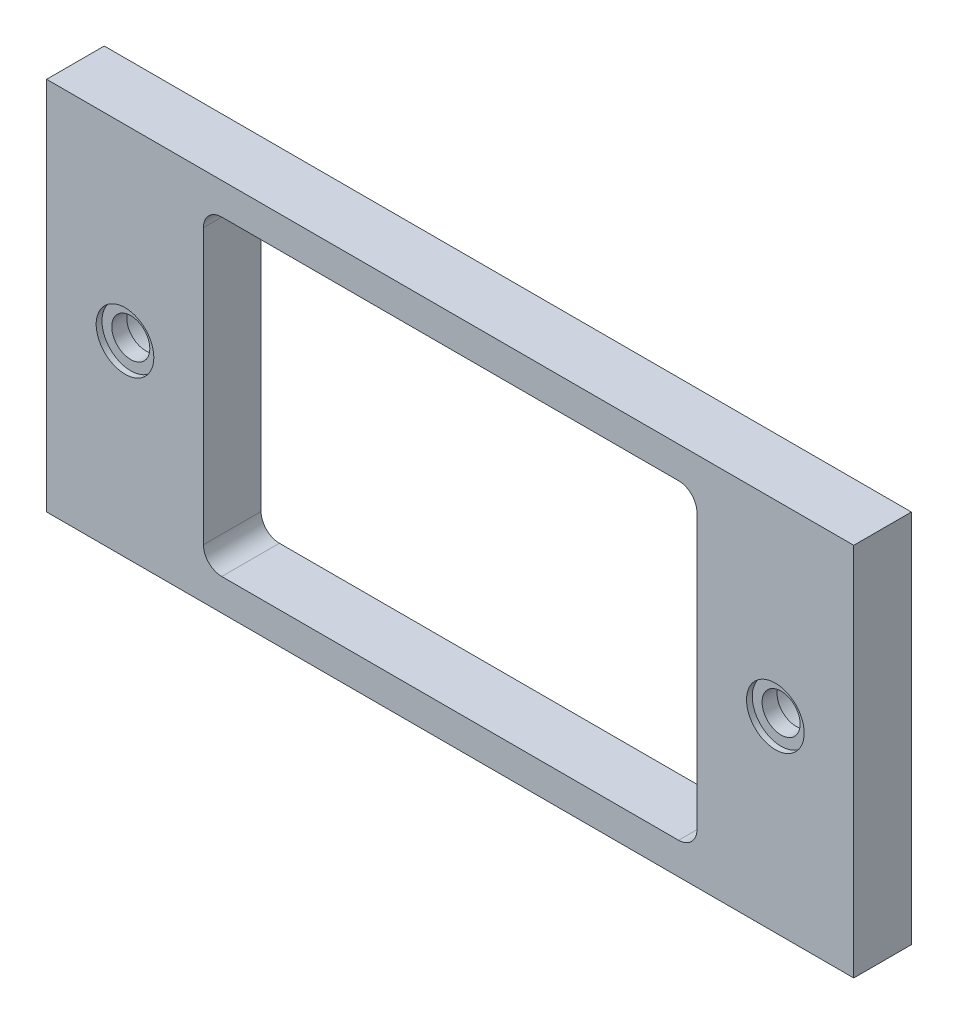
from build123d import *

# Parameters (mm, degrees)
SKETCH_1_W                   = 140
SKETCH_1_H                   = 65
EXTRUDE_1_DEPTH              = 10
SKETCH_2_W                   = 85.6
SKETCH_2_H                   = 54
CUT_EXTRUDE_1_DEPTH          = 11
FILLET_1_R                   = 3.18
HOLE_WIZARD_M6_1_D           = 6.6
HOLE_WIZARD_M6_1_DEPTH       = 15
HOLE_WIZARD_M6_1_CBORE_D     = 11
HOLE_WIZARD_M6_1_CBORE_DEPTH = 6.4
HOLE_WIZARD_M6_1_TIP         = 1.982840043
SKETCH_6_R                   = 5
CUT_EXTRUDE_3_DEPTH          = 1


with BuildPart() as part:
    # 草图1 → 凸台-拉伸1 (new body)
    with BuildSketch(Plane.XY):
        with Locations((70, 32.5)):
            Rectangle(SKETCH_1_W, SKETCH_1_H)
    extrude(amount=EXTRUDE_1_DEPTH)

    # 草图2 → 切除-拉伸1 (cut, through all)
    with BuildSketch(Plane.XY.offset(10)):
        with Locations((70, 32.5)):
            Rectangle(SKETCH_2_W, SKETCH_2_H)
    extrude(amount=-CUT_EXTRUDE_1_DEPTH, mode=Mode.SUBTRACT)

    # 圆角1
    fillet_1_edges = [part.edges().sort_by_distance(p)[0] for p in [
        (27.2, 5.5, 5),
        (27.2, 59.5, 5),
        (112.8, 59.5, 5),
        (112.8, 5.5, 5),
    ]]
    fillet(fillet_1_edges, radius=FILLET_1_R)

    # M6 六角凹头螺钉的柱形沉头孔1
    with Locations(Plane(origin=(0, 0, 0), x_dir=(-1, 0, 0), z_dir=(0, 0, -1))):
        with Locations((-126.4, 32.5), (-13.6, 32.5)):
            CounterBoreHole(HOLE_WIZARD_M6_1_D / 2, HOLE_WIZARD_M6_1_CBORE_D / 2, HOLE_WIZARD_M6_1_CBORE_DEPTH, depth=HOLE_WIZARD_M6_1_DEPTH)
            with Locations((0, 0, -(HOLE_WIZARD_M6_1_DEPTH + HOLE_WIZARD_M6_1_TIP / 2))):  # 118° drill point
                Cone(0, HOLE_WIZARD_M6_1_D / 2, HOLE_WIZARD_M6_1_TIP, mode=Mode.SUBTRACT)

    # 草图6 → 切除-拉伸3 (cut)
    with BuildSketch(Plane.XY.offset(10)):
        with Locations((13.6, 32.5)):
            Circle(SKETCH_6_R)
        with Locations((126.4, 32.5)):
            Circle(SKETCH_6_R)
    extrude(amount=-CUT_EXTRUDE_3_DEPTH, mode=Mode.SUBTRACT)


solid = part.part
